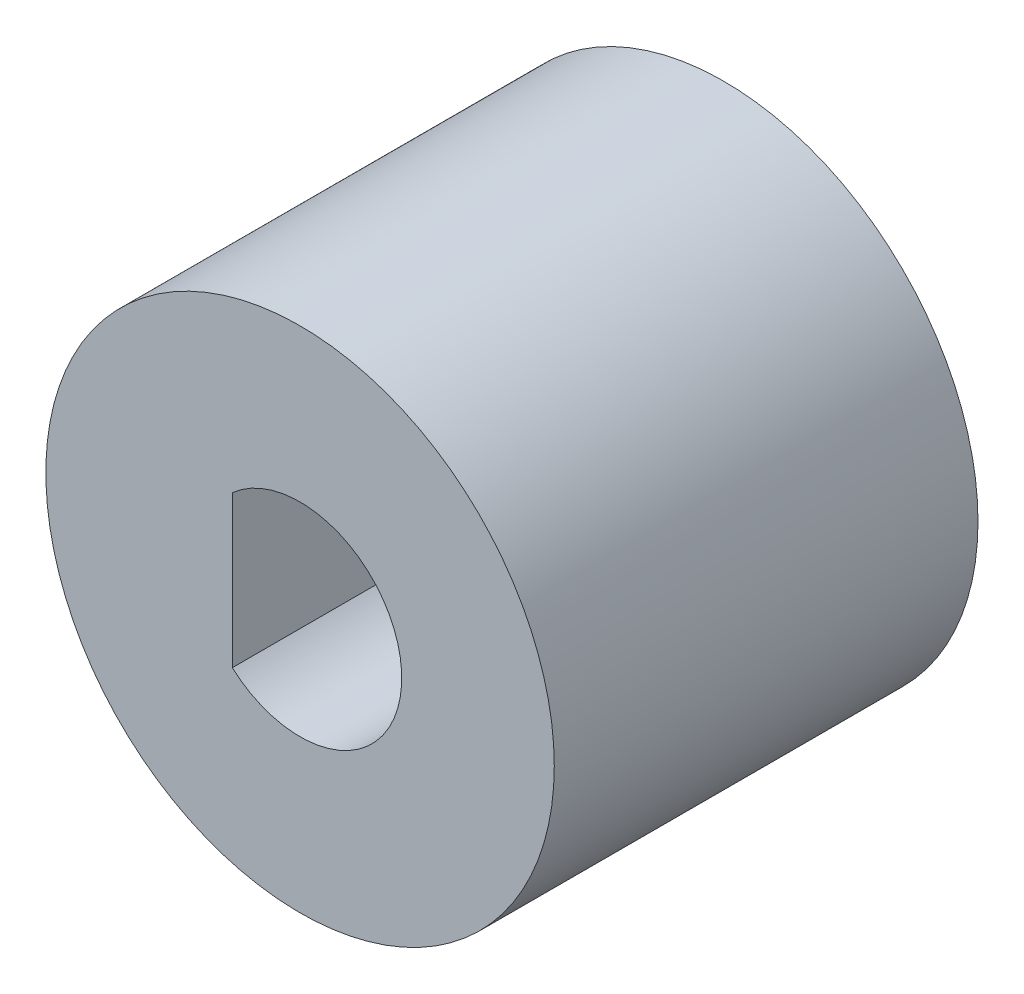
from build123d import *

# Parameters (mm, degrees)
BOSS_EXTRU_1_DEPTH = 25


with BuildPart() as part:
    # Esquisse2 → Boss.-Extru.1 (new body)
    with BuildSketch(Plane.XY):
        with BuildLine():
            ThreePointArc((-4, 4.472135955), (-2.140932539, 5.605034154), (0, 6))
            Line((0, 6), (0, 15))
            ThreePointArc((0, 15), (-2.018355219, 14.863587797), (-4, 14.456832295))
            Line((-4, 14.456832295), (-4, 4.472135955))
        make_face()
        with BuildLine():
            Line((0, 15), (0, 6))
            ThreePointArc((0, 6), (4.242640687, 4.242640687), (6, 0))
            ThreePointArc((6, 0), (2.449489743, -5.477225575), (-4, -4.472135955))
            Line((-4, -4.472135955), (-4, -14.456832295))
            ThreePointArc((-4, -14.456832295), (9.082951062, -11.937336386), (15, 0))
            ThreePointArc((15, 0), (10.606601718, 10.606601718), (0, 15))
        make_face()
        with BuildLine():
            ThreePointArc((-4, -4.472135955), (-6, 0), (-4, 4.472135955))
            Line((-4, 4.472135955), (-4, 14.456832295))
            ThreePointArc((-4, 14.456832295), (-15, 0), (-4, -14.456832295))
            Line((-4, -14.456832295), (-4, -4.472135955))
        make_face()
        with BuildLine():
            Line((-4, -4.472135955), (-4, 4.472135955))
            ThreePointArc((-4, 4.472135955), (-6, 0), (-4, -4.472135955))
        make_face()
    extrude(amount=BOSS_EXTRU_1_DEPTH)


solid = part.part
